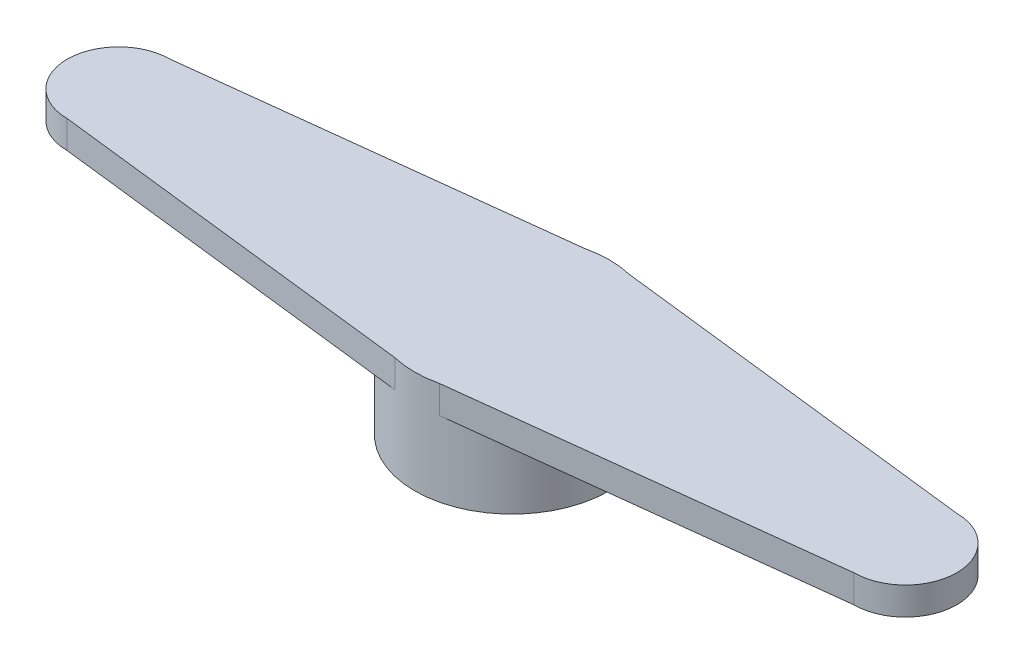
from build123d import *

# Parameters (mm, degrees)
CROQUIS1_R              = 3.5
CROQUIS1_R_2            = 2.5
SALIENTE_EXTRUIR1_DEPTH = 3.7
SALIENTE_EXTRUIR2_DEPTH = 1


with BuildPart() as part:
    # Croquis1 → Saliente-Extruir1 (new body)
    with BuildSketch(Plane(origin=(0, 0, 0), x_dir=(1, 0, 0), z_dir=(0, 1, 0))):
        Circle(CROQUIS1_R)
        Circle(CROQUIS1_R_2, mode=Mode.SUBTRACT)
    extrude(amount=SALIENTE_EXTRUIR1_DEPTH)

    # Croquis2 → Saliente-Extruir2 (add)
    with BuildSketch(Plane(origin=(0, 3.7, 0), x_dir=(1, 0, 0), z_dir=(0, 1, 0))):
        with BuildLine():
            Line((-14.15, 1.85), (0, 3.5))
            Line((0, 3.5), (14.15, 1.85))
            ThreePointArc((14.15, 1.85), (16, 0), (14.15, -1.85))
            Line((14.15, -1.85), (0, -3.5))
            Line((0, -3.5), (-14.15, -1.85))
            ThreePointArc((-14.15, -1.85), (-16, 0), (-14.15, 1.85))
        make_face()
    extrude(amount=-SALIENTE_EXTRUIR2_DEPTH)


solid = part.part
